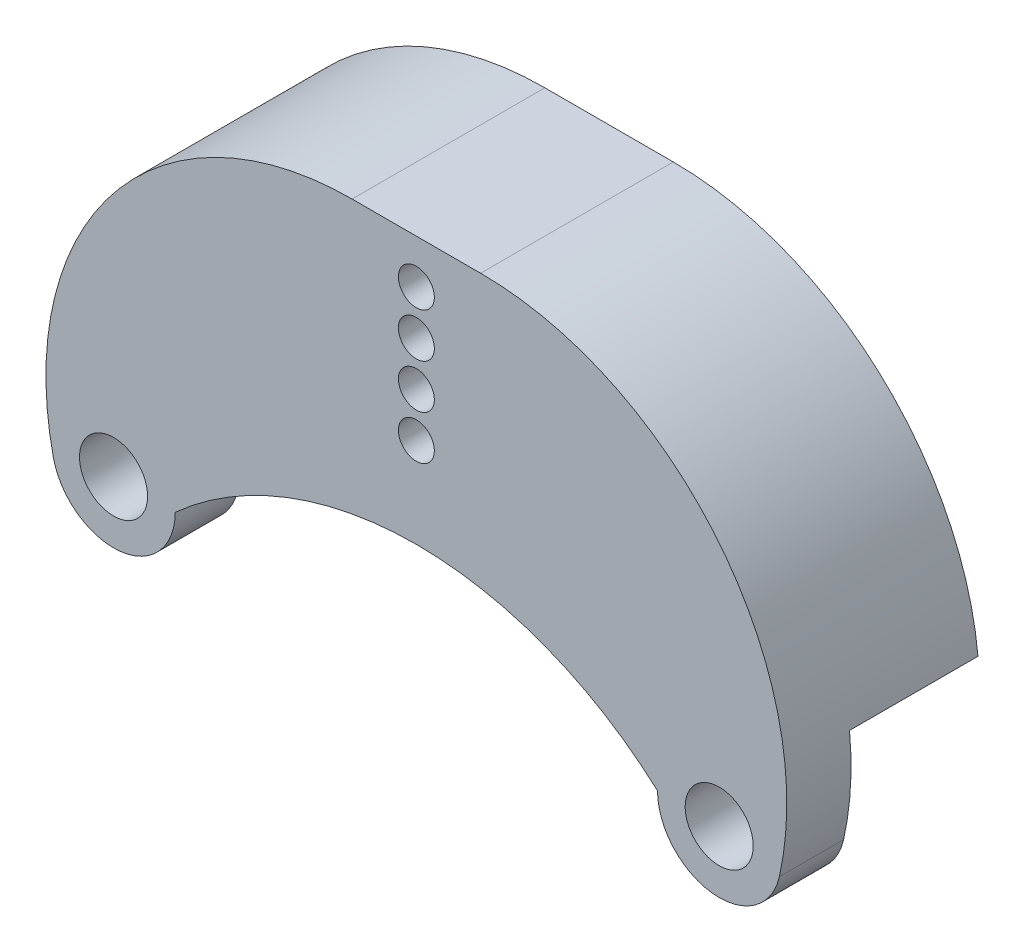
from build123d import *

# Parameters (mm, degrees)
SKETCH1_R           = 2.65
BOSS_EXTRUDE1_DEPTH = 5
BOSS_EXTRUDE2_DEPTH = 10
SKETCH3_R           = 1.4
CUT_EXTRUDE1_DEPTH  = 16


with BuildPart() as part:
    # Sketch1 → Boss-Extrude1 (new body)
    with BuildSketch(Plane.XY):
        with BuildLine():
            Line((5, 28), (-5, 28))
            ThreePointArc((-5, 28), (-23.605754448, 19.060621125), (-28.253479924, -1.05119732))
            ThreePointArc((-28.253479924, -1.05119732), (-23.041182278, -4.770781049), (-18.77, 0))
            ThreePointArc((-18.77, 0), (0, 7.222918877), (18.77, 0))
            ThreePointArc((18.77, 0), (23.041182278, -4.770781049), (28.253479924, -1.05119732))
            ThreePointArc((28.253479924, -1.05119732), (23.605754448, 19.060621125), (5, 28))
        make_face()
        with Locations((-23.57, 0)):
            Circle(SKETCH1_R, mode=Mode.SUBTRACT)
        with Locations((23.57, 0)):
            Circle(SKETCH1_R, mode=Mode.SUBTRACT)
    extrude(amount=BOSS_EXTRUDE1_DEPTH)

    # Sketch2 → Boss-Extrude2 (add)
    with BuildSketch(Plane(origin=(0, 0, 0), x_dir=(-1, 0, 0), z_dir=(0, 0, -1))):
        with BuildLine():
            Line((-28.713948761, 6.537166667), (-6.158885262, 6.537166667))
            ThreePointArc((-6.158885262, 6.537166667), (0, 7.222918877), (6.158885262, 6.537166667))
            Line((6.158885262, 6.537166667), (28.713948761, 6.537166667))
            ThreePointArc((28.713948761, 6.537166667), (20.992221394, 21.837553063), (5, 28))
            Line((5, 28), (-5, 28))
            ThreePointArc((-5, 28), (-20.992221394, 21.837553063), (-28.713948761, 6.537166667))
        make_face()
    extrude(amount=BOSS_EXTRUDE2_DEPTH)

    # Sketch3 → Cut-Extrude1 (cut, through all)
    with BuildSketch(Plane(origin=(0, 0, -10), x_dir=(-1, 0, 0), z_dir=(0, 0, -1))):
        with Locations((0, 24.572918877)):
            Circle(SKETCH3_R)
        with Locations((0, 21.122918877)):
            Circle(SKETCH3_R)
        with Locations((0, 17.672918877)):
            Circle(SKETCH3_R)
        with Locations((0, 14.222918877)):
            Circle(SKETCH3_R)
    extrude(amount=-CUT_EXTRUDE1_DEPTH, mode=Mode.SUBTRACT)


solid = part.part
